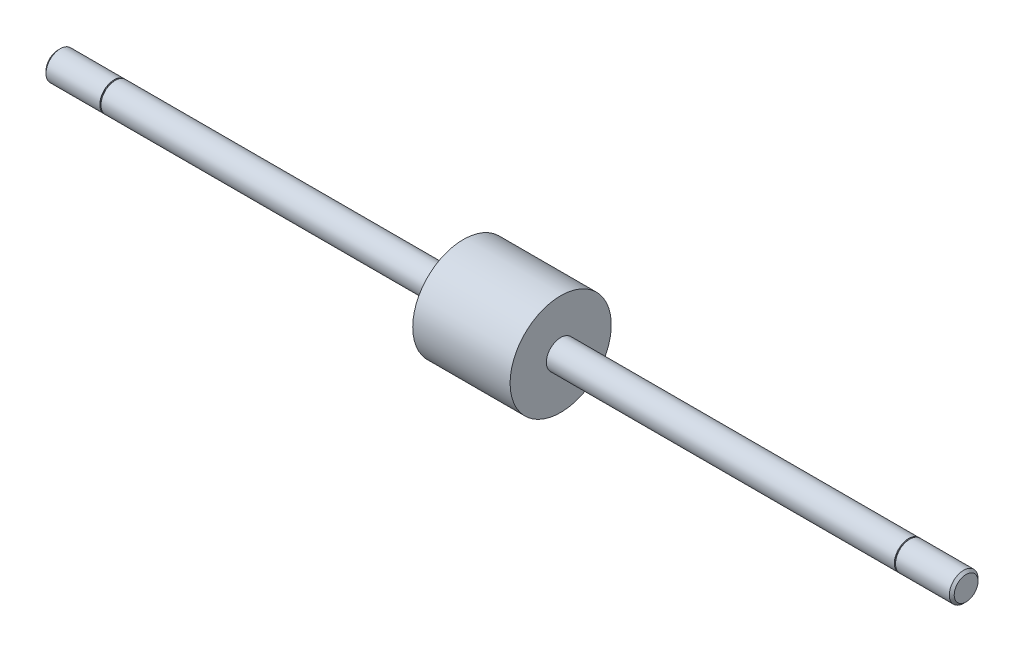
from build123d import *

# Parameters (mm, degrees)
SKETCH3_W = 76.9874
SKETCH3_H = 3.175
SKETCH5_W = 0.254
SKETCH5_H = 0.508
SKETCH6_W = 0.254
SKETCH6_H = 0.508


with BuildPart() as part:
    # Sketch1 → Revolve1 (revolve)
    with BuildSketch(Plane.XY):
        Polygon((0, 0), (0, 3.175), (76.9874, 3.175), (76.9874, 11.19505), (98.5266, 11.19505), (98.5266, 0), align=None)
    revolve(axis=Axis((98.5266, 0, 0), (-1, 0, 0)))

    # Sketch2 → Revolve2 (revolve)
    with BuildSketch(Plane.XY):
        Polygon((-12.7, 0), (-12.7, 2.63398), (-12.15898, 3.175), (0, 3.175), (0, 0), align=None)
    revolve(axis=Axis((0, 0, 0), (-1, 0, 0)))

    # Sketch3 → Revolve3 (revolve)
    with BuildSketch(Plane.XY):
        with Locations((137.0203, 1.5875)):
            Rectangle(SKETCH3_W, SKETCH3_H)
    revolve(axis=Axis((175.514, 0, 0), (-1, 0, 0)))

    # Sketch4 → Revolve4 (revolve)
    with BuildSketch(Plane.XY):
        Polygon((175.514, 0), (175.514, 3.175), (187.67298, 3.175), (188.214, 2.63398), (188.214, 0), align=None)
    revolve(axis=Axis((188.214, 0, 0), (-1, 0, 0)))

    # Sketch5 → Cut-Revolve1 (revolve, cut)
    with BuildSketch(Plane.XY):
        with Locations((-0.127, 3.175)):
            Rectangle(SKETCH5_W, SKETCH5_H)
    revolve(axis=Axis((0, 0, 0), (-1, 0, 0)), mode=Mode.SUBTRACT)

    # Sketch6 → Cut-Revolve2 (revolve, cut)
    with BuildSketch(Plane.XY):
        with Locations((175.641, 3.175)):
            Rectangle(SKETCH6_W, SKETCH6_H)
    revolve(axis=Axis((175.768, 0, 0), (-1, 0, 0)), mode=Mode.SUBTRACT)


solid = part.part
